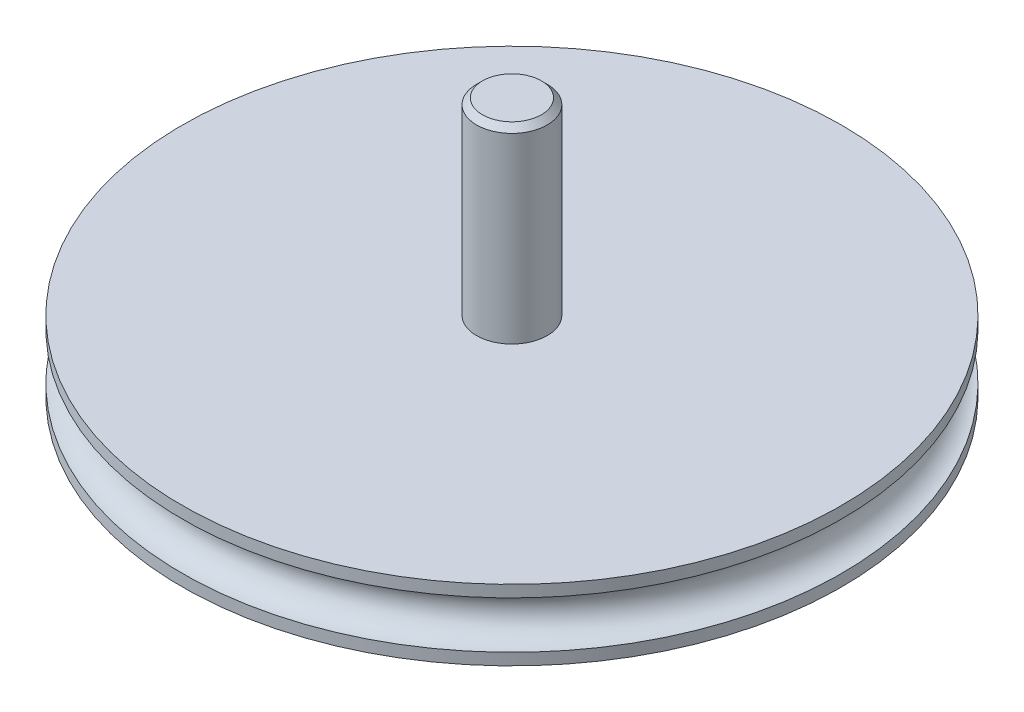
from build123d import *

# Parameters (mm, degrees)
ESQUISSE1_R        = 3
BOSS_EXTRU_1_DEPTH = 16
CHANFREIN1_SIZE    = 0.5


with BuildPart() as part:
    # Esquisse1 → Boss.-Extru.1 (new body)
    with BuildSketch(Plane(origin=(0, 0, 0), x_dir=(1, 0, 0), z_dir=(0, 1, 0))):
        Circle(ESQUISSE1_R)
    extrude(amount=BOSS_EXTRU_1_DEPTH)

    # Esquisse4 → Révolution1 (revolve)
    with BuildSketch(Plane(origin=(0, 0, 0), x_dir=(0, 0, -1), z_dir=(1, 0, 0))):
        with BuildLine():
            Line((0, 0), (28, 0))
            Line((28, 0), (28, -1))
            ThreePointArc((28, -1), (26, -3), (28, -5))
            Line((28, -5), (28, -6))
            Line((28, -6), (0, -6))
            Line((0, -6), (0, 0))
        make_face()
    revolve(axis=Axis((0, -6, 0), (0, 1, 0)))

    # Chanfrein1
    chanfrein1_edges = [part.edges().sort_by_distance(p)[0] for p in [
        (-3, 16, 0),
    ]]
    chamfer(chanfrein1_edges, length=CHANFREIN1_SIZE)


solid = part.part
